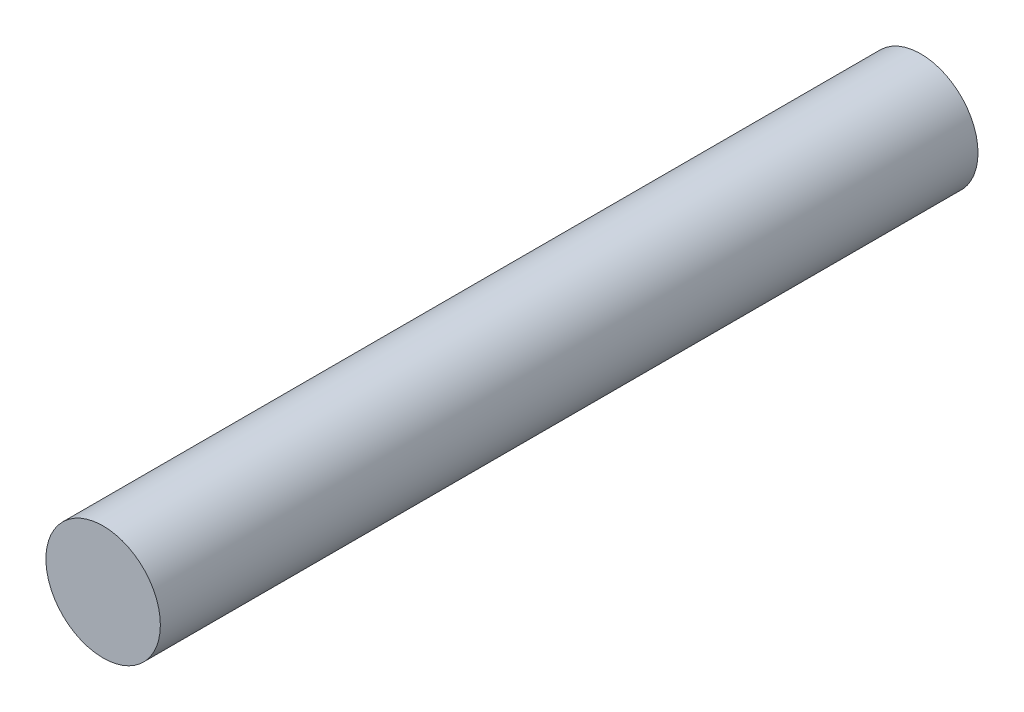
from build123d import *

# Parameters (mm, degrees)
SKETCH_1_R      = 3.85
EXTRUDE_1_DEPTH = 55


with BuildPart() as part:
    # Эскиз1 → Бобышка-Вытянуть1 (new body)
    with BuildSketch(Plane.XY):
        Circle(SKETCH_1_R)
    extrude(amount=EXTRUDE_1_DEPTH)


solid = part.part
